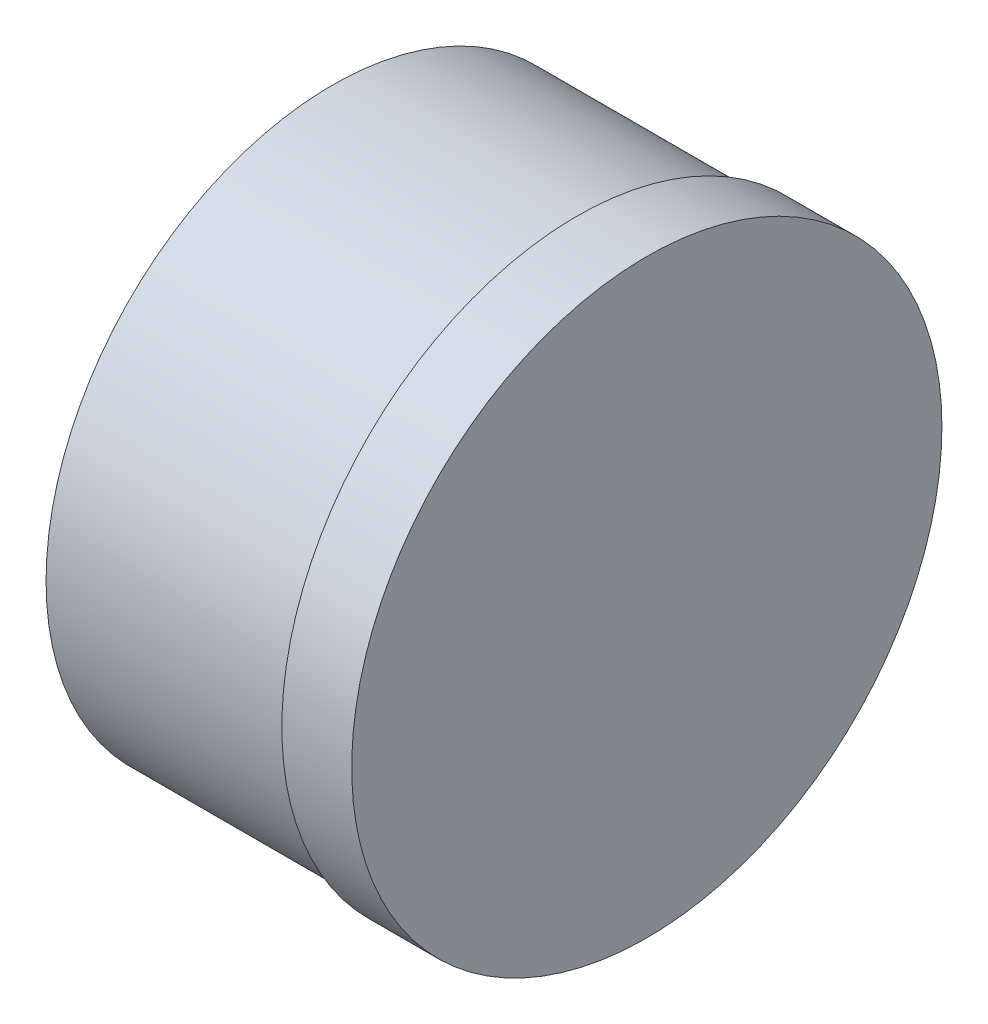
from build123d import *

# Parameters (mm, degrees)
SKETCH1_R           = 41
BOSS_EXTRUDE1_DEPTH = 35
SKETCH2_R           = 42.25
BOSS_EXTRUDE2_DEPTH = 10


with BuildPart() as part:
    # Sketch1 → Boss-Extrude1 (new body)
    with BuildSketch(Plane(origin=(0, 0, 0), x_dir=(0, 0, -1), z_dir=(1, 0, 0))):
        Circle(SKETCH1_R)
    extrude(amount=BOSS_EXTRUDE1_DEPTH)

    # Sketch2 → Boss-Extrude2 (add)
    with BuildSketch(Plane(origin=(35, 0, 0), x_dir=(0, 0, -1), z_dir=(1, 0, 0))):
        Circle(SKETCH2_R)
    extrude(amount=BOSS_EXTRUDE2_DEPTH)


solid = part.part
